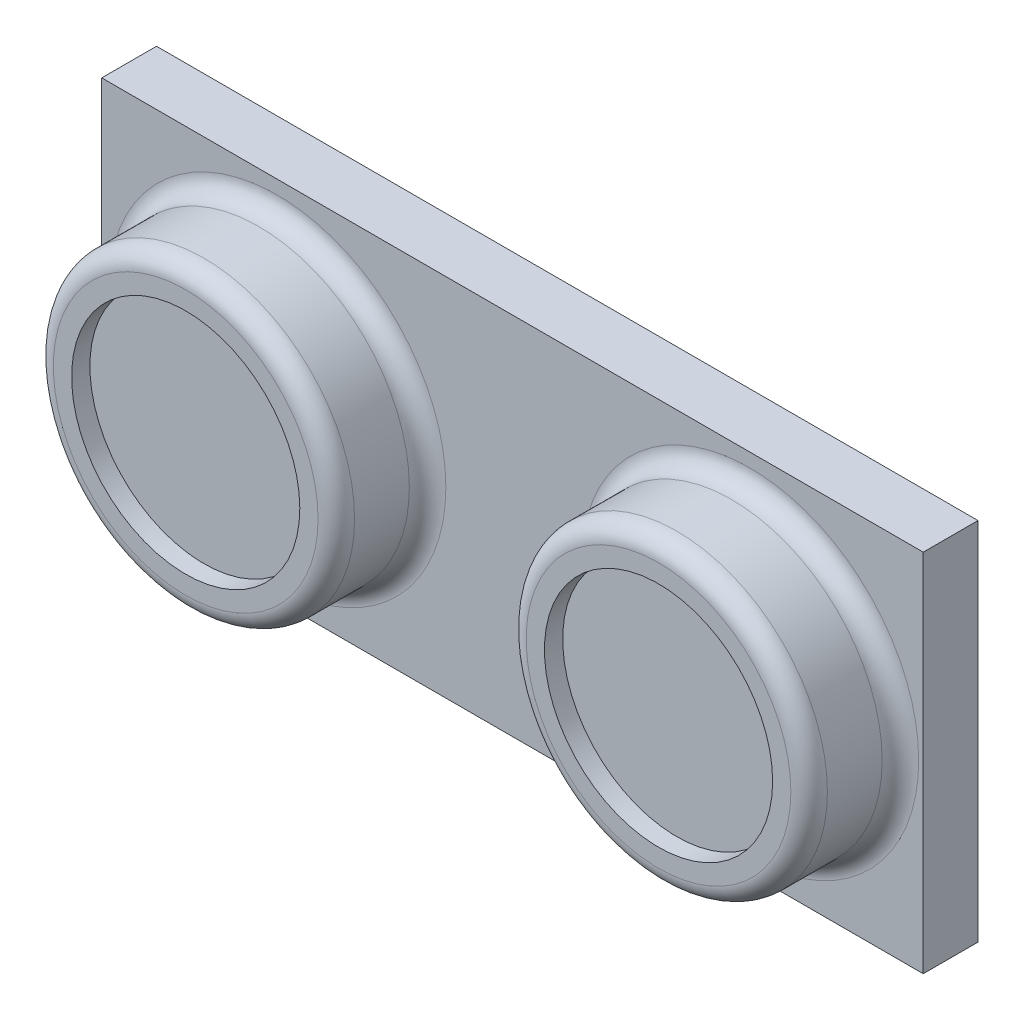
from build123d import *

# Parameters (mm, degrees)
SKETCH_1_W          = 45
SKETCH_1_H          = 20
EXTRUDE_1_DEPTH     = 3
SKETCH_1_3_R        = 8.25
EXTRUDE_2_DEPTH     = 8
SKETCH_2_R          = 6.25
CUT_EXTRUDE_1_DEPTH = 1
FILLET_1_R          = 1


with BuildPart() as part:
    # 草图1 → 凸台-拉伸1 (new body)
    with BuildSketch(Plane.XY):
        Rectangle(SKETCH_1_W, SKETCH_1_H)
    extrude(amount=EXTRUDE_1_DEPTH)

    # 草图1<3> → 凸台-拉伸2 (add)
    with BuildSketch(Plane.XY):
        with Locations((-12.9, 0)):
            Circle(SKETCH_1_3_R)
        with Locations((13, 0)):
            Circle(SKETCH_1_3_R)
    extrude(amount=EXTRUDE_2_DEPTH)

    # 草图2 → 切除-拉伸1 (cut)
    with BuildSketch(Plane.XY.offset(8)):
        with Locations((13, 0)):
            Circle(SKETCH_2_R)
        with Locations((-12.9, 0)):
            Circle(SKETCH_2_R)
    extrude(amount=-CUT_EXTRUDE_1_DEPTH, mode=Mode.SUBTRACT)

    # 圆角1
    fillet_1_edges = [part.edges().sort_by_distance(p)[0] for p in [
        (4.75, 0, 8),
        (4.75, 0, 3),
        (-21.15, 0, 8),
        (-21.15, 0, 3),
    ]]
    fillet(fillet_1_edges, radius=FILLET_1_R)


solid = part.part
